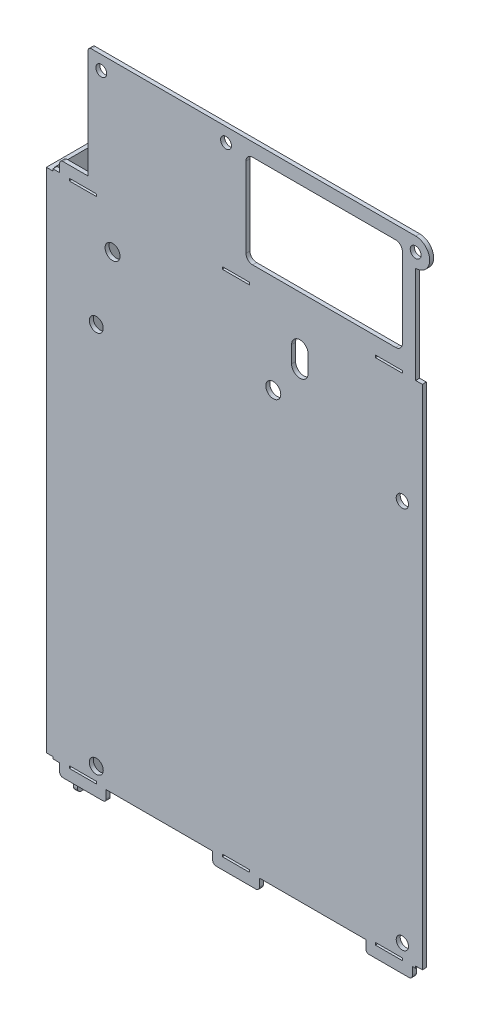
from build123d import *

# Parameters (mm, degrees)
SKETCH2_W           = 113.00010125
SKETCH2_H           = 190.5995575
SKETCH2_R           = 2.1
SKETCH2_R_2         = 1.85
BOSS_EXTRUDE1_DEPTH = 1.2
SKETCH5_W           = 2
SKETCH5_H           = 37.6
SKETCH5_H_2         = 0.6
CUT_EXTRUDE2_DEPTH  = 2.2
CUT_EXTRUDE1_DEPTH  = 2.2
SKETCH9_W           = 14
SKETCH9_H           = 3.4
SKETCH9_W_2         = 8.5
BOSS_EXTRUDE5_DEPTH = 1.2
FILLET1_R           = 1
CUT_EXTRUDE4_REACH  = 3.2
SKETCH10_W          = 8.2
SKETCH10_H          = 0.7
SKETCH11_R          = 2.25
CUT_EXTRUDE5_DEPTH  = 2.2
BOSS_EXTRUDE6_DEPTH = 1.2
SKETCH13_R          = 1.635773904
CUT_EXTRUDE6_DEPTH  = 2.2
SKETCH14_W          = 1.2
SKETCH14_H          = 152.3995575
BOSS_EXTRUDE7_DEPTH = 32
BOSS_EXTRUDE8_DEPTH = 1.2
BOSS_EXTRUDE9_DEPTH = 1.2
CUT_EXTRUDE7_REACH  = 117.2
FILLET2_R           = 1


with BuildPart() as part:
    # Sketch2 → Boss-Extrude1 (new body)
    with BuildSketch(Plane.XY):
        with Locations((49.667238625, 126.88082875)):
            Rectangle(SKETCH2_W, SKETCH2_H)
        with Locations((8.16763175, 151.180160625)):
            Circle(SKETCH2_R, mode=Mode.SUBTRACT)
        with Locations((100.1668405, 151.180160625)):
            Circle(SKETCH2_R_2, mode=Mode.SUBTRACT)
        with Locations((100.1668405, 36.181495)):
            Circle(SKETCH2_R_2, mode=Mode.SUBTRACT)
        with Locations((8.16763175, 36.181495)):
            Circle(SKETCH2_R, mode=Mode.SUBTRACT)
    extrude(amount=BOSS_EXTRUDE1_DEPTH)

    # Sketch5 → Cut-Extrude2 (cut, through all)
    with BuildSketch(Plane.XY.offset(1.2)):
        Polygon((-4.832812, 185.1806075), (5.667188, 185.1806075), (5.667188, 222.1806075), (-6.832812, 222.1806075), (-6.832812, 185.1806075), (-6.832812, 184.5806075), (-4.832812, 184.5806075), align=None)
        with Locations((105.16728925, 203.3806075)):
            Rectangle(SKETCH5_W, SKETCH5_H)
        with Locations((-5.832812, 31.88105)):
            Rectangle(SKETCH5_W, SKETCH5_H_2)
        with Locations((105.16728925, 31.88105)):
            Rectangle(SKETCH5_W, SKETCH5_H_2)
    extrude(amount=-CUT_EXTRUDE2_DEPTH, mode=Mode.SUBTRACT)

    # Sketch4 → Cut-Extrude1 (cut, through all)
    with BuildSketch(Plane.XY.offset(1.2)):
        with BuildLine():
            Line((55.16728925, 218.1806075), (98.16728925, 218.1806075))
            ThreePointArc((98.16728925, 218.1806075), (99.581502812, 217.594821062), (100.16728925, 216.1806075))
            Line((100.16728925, 216.1806075), (100.16728925, 192.1806075))
            ThreePointArc((100.16728925, 192.1806075), (99.581502812, 190.766393938), (98.16728925, 190.1806075))
            Line((98.16728925, 190.1806075), (55.16728925, 190.1806075))
            ThreePointArc((55.16728925, 190.1806075), (53.753075688, 190.766393938), (53.16728925, 192.1806075))
            Line((53.16728925, 192.1806075), (53.16728925, 216.1806075))
            ThreePointArc((53.16728925, 216.1806075), (53.753075688, 217.594821062), (55.16728925, 218.1806075))
        make_face()
    extrude(amount=-CUT_EXTRUDE1_DEPTH, mode=Mode.SUBTRACT)

    # Sketch9 → Boss-Extrude5 (add)
    with BuildSketch(Plane.XY.offset(1.2)):
        with Locations((4.167188, 29.88105)):
            Rectangle(SKETCH9_W, SKETCH9_H)
        with Locations((96.16728925, 29.88105)):
            Rectangle(SKETCH9_W, SKETCH9_H)
        with Locations((50.167238625, 29.88105)):
            Rectangle(SKETCH9_W, SKETCH9_H)
        with Locations((1.417188, 186.8806075)):
            Rectangle(SKETCH9_W_2, SKETCH9_H)
    extrude(amount=-BOSS_EXTRUDE5_DEPTH)

    # Fillet1
    fillet1_edges = [part.edges().sort_by_distance(p)[0] for p in [
        (103.16728925, 28.18105, 0.6),
        (89.16728925, 28.18105, 0.6),
        (57.167238625, 28.18105, 0.6),
        (43.167238625, 28.18105, 0.6),
        (11.167188, 28.18105, 0.6),
        (-2.832812, 28.18105, 0.6),
        (-2.832812, 188.5806075, 0.6),
    ]]
    fillet(fillet1_edges, radius=FILLET1_R)

    # Sketch10 → Cut-Extrude4 (cut, up to next)
    with BuildSketch(Plane.XY.offset(1.2), mode=Mode.PRIVATE) as cut_extrude4_sk1:
        with Locations((96.16728925, 31.93105)):
            Rectangle(SKETCH10_W, SKETCH10_H)
    cut_extrude4_tool1 = extrude(cut_extrude4_sk1.sketch, amount=-CUT_EXTRUDE4_REACH, mode=Mode.PRIVATE) & part.part
    add(cut_extrude4_tool1.solids().sort_by_distance((96.167289, 31.93105, 1.2))[0], mode=Mode.SUBTRACT)
    # Sketch10 → Cut-Extrude4 (cut, up to next)
    with BuildSketch(Plane.XY.offset(1.2), mode=Mode.PRIVATE) as cut_extrude4_sk2:
        with Locations((50.167238625, 31.93105)):
            Rectangle(SKETCH10_W, SKETCH10_H)
    cut_extrude4_tool2 = extrude(cut_extrude4_sk2.sketch, amount=-CUT_EXTRUDE4_REACH, mode=Mode.PRIVATE) & part.part
    add(cut_extrude4_tool2.solids().sort_by_distance((50.167239, 31.93105, 1.2))[0], mode=Mode.SUBTRACT)
    # Sketch10 → Cut-Extrude4 (cut, up to next)
    with BuildSketch(Plane.XY.offset(1.2), mode=Mode.PRIVATE) as cut_extrude4_sk3:
        with Locations((4.167188, 31.93105)):
            Rectangle(SKETCH10_W, SKETCH10_H)
    cut_extrude4_tool3 = extrude(cut_extrude4_sk3.sketch, amount=-CUT_EXTRUDE4_REACH, mode=Mode.PRIVATE) & part.part
    add(cut_extrude4_tool3.solids().sort_by_distance((4.167188, 31.93105, 1.2))[0], mode=Mode.SUBTRACT)
    # Sketch10 → Cut-Extrude4 (cut, up to next)
    with BuildSketch(Plane.XY.offset(1.2), mode=Mode.PRIVATE) as cut_extrude4_sk4:
        with Locations((50.167238625, 184.8306075)):
            Rectangle(SKETCH10_W, SKETCH10_H)
    cut_extrude4_tool4 = extrude(cut_extrude4_sk4.sketch, amount=-CUT_EXTRUDE4_REACH, mode=Mode.PRIVATE) & part.part
    add(cut_extrude4_tool4.solids().sort_by_distance((50.167239, 184.830607, 1.2))[0], mode=Mode.SUBTRACT)
    # Sketch10 → Cut-Extrude4 (cut, up to next)
    with BuildSketch(Plane.XY.offset(1.2), mode=Mode.PRIVATE) as cut_extrude4_sk5:
        with Locations((96.16728925, 184.8306075)):
            Rectangle(SKETCH10_W, SKETCH10_H)
    cut_extrude4_tool5 = extrude(cut_extrude4_sk5.sketch, amount=-CUT_EXTRUDE4_REACH, mode=Mode.PRIVATE) & part.part
    add(cut_extrude4_tool5.solids().sort_by_distance((96.167289, 184.830607, 1.2))[0], mode=Mode.SUBTRACT)
    # Sketch10 → Cut-Extrude4 (cut, up to next)
    with BuildSketch(Plane.XY.offset(1.2), mode=Mode.PRIVATE) as cut_extrude4_sk6:
        with Locations((4.167188, 184.8306075)):
            Rectangle(SKETCH10_W, SKETCH10_H)
    cut_extrude4_tool6 = extrude(cut_extrude4_sk6.sketch, amount=-CUT_EXTRUDE4_REACH, mode=Mode.PRIVATE) & part.part
    add(cut_extrude4_tool6.solids().sort_by_distance((4.167188, 184.830607, 1.2))[0], mode=Mode.SUBTRACT)

    # Sketch11 → Cut-Extrude5 (cut, through all)
    with BuildSketch(Plane.XY.offset(1.2)):
        with Locations((61.367697375, 160.67994375)):
            Circle(SKETCH11_R)
        with Locations((13.067697375, 172.47994375)):
            Circle(SKETCH11_R)
        with BuildLine():
            Line((71.867697375, 175.27994375), (71.867697375, 170.27994375))
            ThreePointArc((71.867697375, 170.27994375), (69.367697375, 167.77994375), (66.867697375, 170.27994375))
            Line((66.867697375, 170.27994375), (66.867697375, 175.27994375))
            ThreePointArc((66.867697375, 175.27994375), (69.367697375, 177.77994375), (71.867697375, 175.27994375))
        make_face()
    extrude(amount=-CUT_EXTRUDE5_DEPTH, mode=Mode.SUBTRACT)

    # Sketch12 → Boss-Extrude6 (add)
    with BuildSketch(Plane.XY.offset(1.2)):
        with BuildLine():
            Line((104.16728925, 222.1806075), (104.16728925, 213.7806075))
            ThreePointArc((104.16728925, 213.7806075), (108.36728925, 217.9806075), (104.16728925, 222.1806075))
        make_face()
    extrude(amount=-BOSS_EXTRUDE6_DEPTH)

    # Sketch13 → Cut-Extrude6 (cut, through all)
    with BuildSketch(Plane.XY.offset(1.2)):
        with Locations((104.16728925, 217.9806075)):
            Circle(SKETCH13_R)
        with Locations((47.16728925, 217.9806075)):
            Circle(SKETCH13_R)
        with Locations((9.667188, 217.9806075)):
            Circle(SKETCH13_R)
    extrude(amount=-CUT_EXTRUDE6_DEPTH, mode=Mode.SUBTRACT)

    # Sketch14 → Boss-Extrude7 (add)
    with BuildSketch(Plane(origin=(0, 0, 0), x_dir=(-1, 0, 0), z_dir=(0, 0, -1))):
        with Locations((6.232812, 108.38082875)):
            Rectangle(SKETCH14_W, SKETCH14_H)
    extrude(amount=BOSS_EXTRUDE7_DEPTH)

    # Sketch16 → Boss-Extrude8 (add)
    with BuildSketch(Plane.ZY.offset(6.832812)):
        with BuildLine():
            Line((-32, 32.18105), (-4, 32.18105))
            ThreePointArc((-4, 32.18105), (-6.121320344, 31.302370344), (-7, 29.18105))
            Line((-7, 29.18105), (-7, 18.18105))
            Line((-7, 18.18105), (-32, 18.18105))
            Line((-32, 18.18105), (-32, 32.18105))
        make_face()
    extrude(amount=-BOSS_EXTRUDE8_DEPTH)

    # Sketch17 → Boss-Extrude9 (add)
    with BuildSketch(Plane.ZY.offset(6.832812)):
        with BuildLine():
            Line((-32, 184.5806075), (-38, 184.5806075))
            Line((-38, 184.5806075), (-38, 168.5806075))
            Line((-38, 168.5806075), (-35, 168.5806075))
            ThreePointArc((-35, 168.5806075), (-32.878679656, 167.701927844), (-32, 165.5806075))
            Line((-32, 165.5806075), (-32, 184.5806075))
        make_face()
    extrude(amount=-BOSS_EXTRUDE9_DEPTH)

    # Sketch15 → Cut-Extrude7 (cut, up to next)
    with BuildSketch(Plane.ZY.offset(6.832812), mode=Mode.PRIVATE) as cut_extrude7_sk1:
        with BuildLine():
            Line((-46.8, 177.7806075), (-34.8, 177.7806075))
            ThreePointArc((-34.8, 177.7806075), (-33.2, 176.1806075), (-34.8, 174.5806075))
            Line((-34.8, 174.5806075), (-46.8, 174.5806075))
            ThreePointArc((-46.8, 174.5806075), (-48.4, 176.1806075), (-46.8, 177.7806075))
        make_face()
    cut_extrude7_tool1 = extrude(cut_extrude7_sk1.sketch, amount=-CUT_EXTRUDE7_REACH, mode=Mode.PRIVATE) & part.part
    add(cut_extrude7_tool1.solids().sort_by_distance((-6.832812, 176.180608, -40.8))[0], mode=Mode.SUBTRACT)
    # Sketch15 → Cut-Extrude7 (cut, up to next)
    with BuildSketch(Plane.ZY.offset(6.832812), mode=Mode.PRIVATE) as cut_extrude7_sk2:
        with BuildLine():
            Line((-25.1, 21.18105), (-25.1, 18.18105))
            Line((-25.1, 18.18105), (-21.9, 18.18105))
            Line((-21.9, 18.18105), (-21.9, 21.18105))
            ThreePointArc((-21.9, 21.18105), (-23.5, 22.78105), (-25.1, 21.18105))
        make_face()
    cut_extrude7_tool2 = extrude(cut_extrude7_sk2.sketch, amount=-CUT_EXTRUDE7_REACH, mode=Mode.PRIVATE) & part.part
    add(cut_extrude7_tool2.solids().sort_by_distance((-6.832812, 20.324349, -23.5))[0], mode=Mode.SUBTRACT)

    # Fillet2
    fillet2_edges = [part.edges().sort_by_distance(p)[0] for p in [
        (5.667188, 222.1806075, 0.6),
        (-6.232812, 18.18105, -32),
        (-6.232812, 18.18105, -7),
        (-6.232812, 168.5806075, -38),
        (-6.232812, 184.5806075, -38),
    ]]
    fillet(fillet2_edges, radius=FILLET2_R)


solid = part.part
